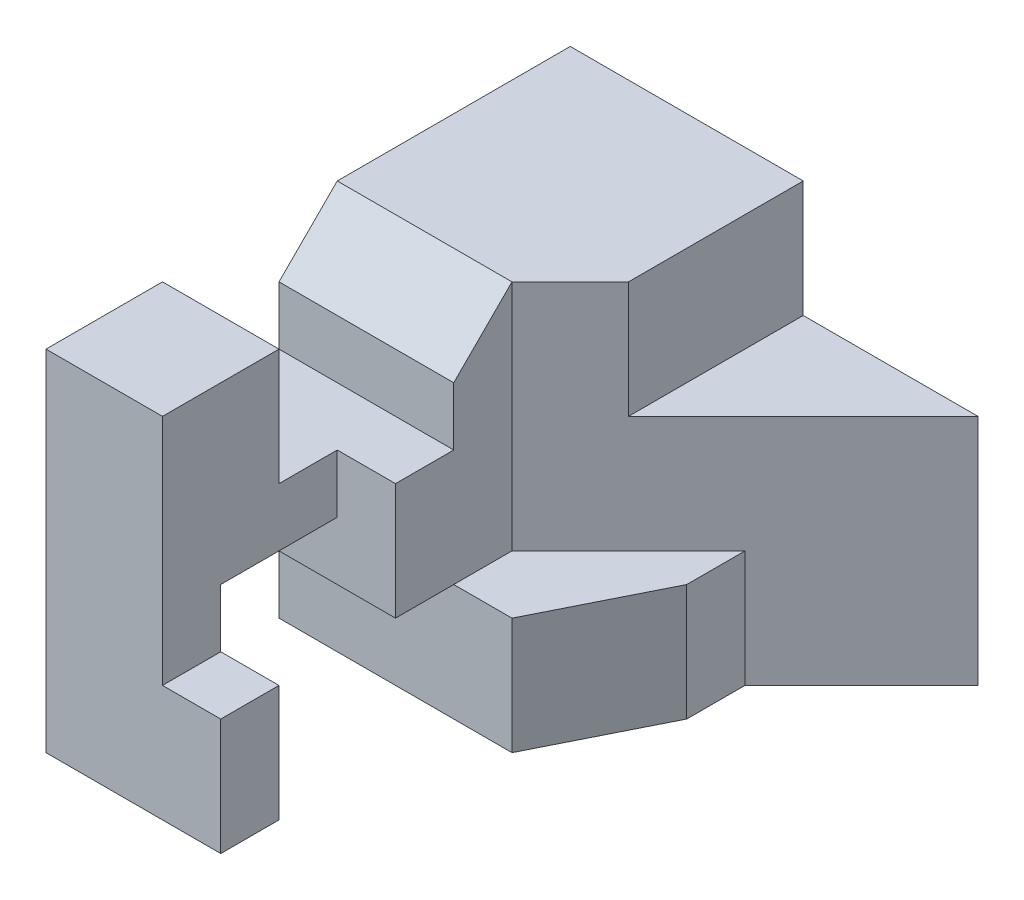
from build123d import *

# Parameters (mm, degrees)
SKETCH1_W           = 7
SKETCH1_H           = 6
BOSS_EXTRUDE1_DEPTH = 9
CUT_EXTRUDE1_DEPTH  = 2
CUT_EXTRUDE3_DEPTH  = 4
CUT_EXTRUDE4_DEPTH  = 7
SKETCH5_W           = 3
SKETCH5_H           = 2
CUT_EXTRUDE5_DEPTH  = 5
CUT_EXTRUDE8_DEPTH  = 4
CUT_EXTRUDE9_DEPTH  = 4
SKETCH11_W          = 2
SKETCH11_H          = 1
CUT_EXTRUDE12_DEPTH = 4
CUT_EXTRUDE13_DEPTH = 1
SKETCH13_W          = 1
SKETCH13_H          = 1
CUT_EXTRUDE14_DEPTH = 3


with BuildPart() as part:
    # Sketch1 → Boss-Extrude1 (new body)
    with BuildSketch(Plane.XY):
        Rectangle(SKETCH1_W, SKETCH1_H)
    extrude(amount=BOSS_EXTRUDE1_DEPTH)

    # Sketch2 → Cut-Extrude1 (cut)
    with BuildSketch(Plane(origin=(0, 3, 0), x_dir=(1, 0, 0), z_dir=(0, 1, 0))):
        Polygon((3.5, 0), (0.5, 0), (0.5, -3), align=None)
    extrude(amount=-CUT_EXTRUDE1_DEPTH, mode=Mode.SUBTRACT)

    # Sketch3 → Cut-Extrude3 (cut)
    with BuildSketch(Plane(origin=(0, 3, 0), x_dir=(1, 0, 0), z_dir=(0, 1, 0))):
        Polygon((3.5, 0), (0.5, -3), (0.5, -9), (3.5, -9), align=None)
    extrude(amount=-CUT_EXTRUDE3_DEPTH, mode=Mode.SUBTRACT)

    # Sketch4 → Cut-Extrude4 (cut, through all)
    with BuildSketch(Plane(origin=(0, 3, 0), x_dir=(1, 0, 0), z_dir=(0, 1, 0))):
        Polygon((3.5, 0), (1.5, -2), (1.5, -3), (0.5, -5), (0.5, -9), (3.5, -9), align=None)
    extrude(amount=-CUT_EXTRUDE4_DEPTH, mode=Mode.SUBTRACT)

    # Sketch5 → Cut-Extrude5 (cut, through all)
    with BuildSketch(Plane(origin=(0.5, 0, 0), x_dir=(0, 0, -1), z_dir=(1, 0, 0))):
        with Locations((-6.5, -2)):
            Rectangle(SKETCH5_W, SKETCH5_H)
    extrude(amount=-CUT_EXTRUDE5_DEPTH, mode=Mode.SUBTRACT)

    # Sketch7 → Cut-Extrude8 (cut)
    with BuildSketch(Plane(origin=(0, 3, 0), x_dir=(1, 0, 0), z_dir=(0, 1, 0))):
        Polygon((0.5, -3), (-0.5, -4), (-0.5, -9), (0.5, -9), align=None)
    extrude(amount=-CUT_EXTRUDE8_DEPTH, mode=Mode.SUBTRACT)

    # Sketch8 → Cut-Extrude9 (cut, through all)
    with BuildSketch(Plane(origin=(-0.5, 0, 0), x_dir=(0, 0, -1), z_dir=(1, 0, 0))):
        Polygon((-4, 3), (-5, 2), (-5, 1), (-7, 1), (-7, 3), align=None)
    extrude(amount=-CUT_EXTRUDE9_DEPTH, mode=Mode.SUBTRACT)

    # Sketch11 → Cut-Extrude12 (cut, through all)
    with BuildSketch(Plane(origin=(-0.5, 0, 0), x_dir=(0, 0, -1), z_dir=(1, 0, 0))):
        with Locations((-7, -0.5)):
            Rectangle(SKETCH11_W, SKETCH11_H)
    extrude(amount=-CUT_EXTRUDE12_DEPTH, mode=Mode.SUBTRACT)

    # Sketch12 → Cut-Extrude13 (cut)
    with BuildSketch(Plane(origin=(-0.5, 0, 0), x_dir=(0, 0, -1), z_dir=(1, 0, 0))):
        Polygon((-9, 3), (-7, 3), (-7, 1), (-6, 1), (-6, 0), (-8, 0), (-8, -1), (-9, -1), align=None)
    extrude(amount=-CUT_EXTRUDE13_DEPTH, mode=Mode.SUBTRACT)

    # Sketch13 → Cut-Extrude14 (cut, through all)
    with BuildSketch(Plane(origin=(0, -1, 0), x_dir=(1, 0, 0), z_dir=(0, 1, 0))):
        with Locations((0, -8.5)):
            Rectangle(SKETCH13_W, SKETCH13_H)
    extrude(amount=-CUT_EXTRUDE14_DEPTH, mode=Mode.SUBTRACT)


solid = part.part
